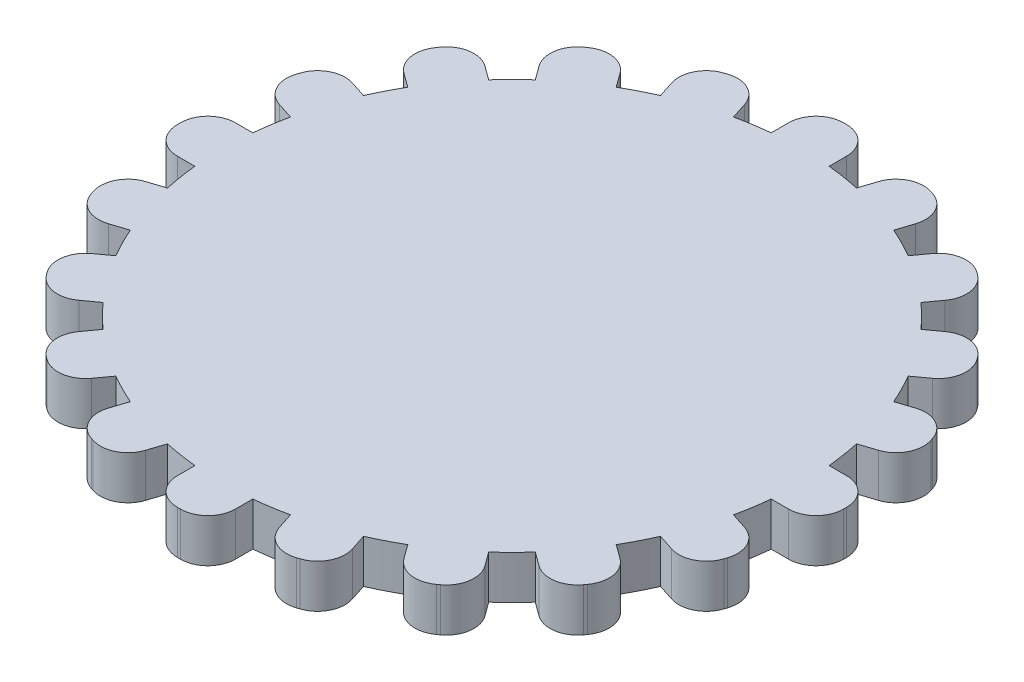
from build123d import *

# Parameters (mm, degrees)
BOSS_EXTRUDE3_DEPTH = 3
BOSS_EXTRUDE4_DEPTH = 3


with BuildPart() as part:
    # Sketch2 → Boss-Extrude3 (new body)
    with BuildSketch(Plane(origin=(0, 0, 0), x_dir=(1, 0, 0), z_dir=(0, 1, 0))):
        with BuildLine():
            Line((-23, -0.1), (-23, 0.1))
            ThreePointArc((-23, 0.1), (-22.443502884, 1.443502884), (-21.1, 2))
            Line((-21.1, 2), (-19.899748742, 2))
            ThreePointArc((-19.899748742, 2), (-19.753766812, 3.128689301), (-19.543819703, 4.247247513))
            Line((-19.543819703, 4.247247513), (-20.685326483, 4.618145549))
            ThreePointArc((-20.685326483, 4.618145549), (-21.791106589, 5.56257098), (-21.905201574, 7.012285219))
            Line((-21.905201574, 7.012285219), (-21.843398175, 7.202496522))
            ThreePointArc((-21.843398175, 7.202496522), (-20.898972744, 8.308276629), (-19.449258505, 8.422371614))
            Line((-19.449258505, 8.422371614), (-18.307751725, 8.051473578))
            ThreePointArc((-18.307751725, 8.051473578), (-17.820130484, 9.079809995), (-17.274805421, 10.078744846))
            Line((-17.274805421, 10.078744846), (-18.245829086, 10.784234835))
            ThreePointArc((-18.245829086, 10.784234835), (-19.005644954, 12.02414164), (-18.666169396, 13.438159103))
            Line((-18.666169396, 13.438159103), (-18.548612345, 13.599962502))
            ThreePointArc((-18.548612345, 13.599962502), (-17.30870554, 14.35977837), (-15.894688077, 14.020302812))
            Line((-15.894688077, 14.020302812), (-14.923664412, 13.314812824))
            ThreePointArc((-14.923664412, 13.314812824), (-14.142135624, 14.142135624), (-13.314812824, 14.923664412))
            Line((-13.314812824, 14.923664412), (-14.020302812, 15.894688077))
            ThreePointArc((-14.020302812, 15.894688077), (-14.35977837, 17.30870554), (-13.599962502, 18.548612345))
            Line((-13.599962502, 18.548612345), (-13.438159103, 18.666169396))
            ThreePointArc((-13.438159103, 18.666169396), (-12.02414164, 19.005644954), (-10.784234835, 18.245829086))
            Line((-10.784234835, 18.245829086), (-10.078744846, 17.274805421))
            ThreePointArc((-10.078744846, 17.274805421), (-9.079809995, 17.820130484), (-8.051473578, 18.307751725))
            Line((-8.051473578, 18.307751725), (-8.422371614, 19.449258505))
            ThreePointArc((-8.422371614, 19.449258505), (-8.308276629, 20.898972744), (-7.202496522, 21.843398175))
            Line((-7.202496522, 21.843398175), (-7.012285219, 21.905201574))
            ThreePointArc((-7.012285219, 21.905201574), (-5.56257098, 21.791106589), (-4.618145549, 20.685326483))
            Line((-4.618145549, 20.685326483), (-4.247247513, 19.543819703))
            ThreePointArc((-4.247247513, 19.543819703), (-3.128689301, 19.753766812), (-2, 19.899748742))
            Line((-2, 19.899748742), (-2, 21.1))
            ThreePointArc((-2, 21.1), (-1.443502884, 22.443502884), (-0.1, 23))
            Line((-0.1, 23), (0.1, 23))
            ThreePointArc((0.1, 23), (1.443502884, 22.443502884), (2, 21.1))
            Line((2, 21.1), (2, 19.899748742))
            ThreePointArc((2, 19.899748742), (3.128689301, 19.753766812), (4.247247513, 19.543819703))
            Line((4.247247513, 19.543819703), (4.618145549, 20.685326483))
            ThreePointArc((4.618145549, 20.685326483), (5.56257098, 21.791106589), (7.012285219, 21.905201574))
            Line((7.012285219, 21.905201574), (7.202496522, 21.843398175))
            ThreePointArc((7.202496522, 21.843398175), (8.308276629, 20.898972744), (8.422371614, 19.449258505))
            Line((8.422371614, 19.449258505), (8.051473578, 18.307751725))
            ThreePointArc((8.051473578, 18.307751725), (9.079809995, 17.820130484), (10.078744846, 17.274805421))
            Line((10.078744846, 17.274805421), (10.784234835, 18.245829086))
            ThreePointArc((10.784234835, 18.245829086), (12.02414164, 19.005644954), (13.438159103, 18.666169396))
            Line((13.438159103, 18.666169396), (13.599962502, 18.548612345))
            ThreePointArc((13.599962502, 18.548612345), (14.35977837, 17.30870554), (14.020302812, 15.894688077))
            Line((14.020302812, 15.894688077), (13.314812824, 14.923664412))
            ThreePointArc((13.314812824, 14.923664412), (14.142135624, 14.142135624), (14.923664412, 13.314812824))
            Line((14.923664412, 13.314812824), (15.894688077, 14.020302812))
            ThreePointArc((15.894688077, 14.020302812), (17.30870554, 14.35977837), (18.548612345, 13.599962502))
            Line((18.548612345, 13.599962502), (18.666169396, 13.438159103))
            ThreePointArc((18.666169396, 13.438159103), (19.005644954, 12.02414164), (18.245829086, 10.784234835))
            Line((18.245829086, 10.784234835), (17.274805421, 10.078744846))
            ThreePointArc((17.274805421, 10.078744846), (17.820130484, 9.079809995), (18.307751725, 8.051473578))
            Line((18.307751725, 8.051473578), (19.449258505, 8.422371614))
            ThreePointArc((19.449258505, 8.422371614), (20.898972744, 8.308276629), (21.843398175, 7.202496522))
            Line((21.843398175, 7.202496522), (21.905201574, 7.012285219))
            ThreePointArc((21.905201574, 7.012285219), (21.791106589, 5.56257098), (20.685326483, 4.618145549))
            Line((20.685326483, 4.618145549), (19.543819703, 4.247247513))
            ThreePointArc((19.543819703, 4.247247513), (19.753766812, 3.128689301), (19.899748742, 2))
            Line((19.899748742, 2), (21.1, 2))
            ThreePointArc((21.1, 2), (22.443502884, 1.443502884), (23, 0.1))
            Line((23, 0.1), (23, -0.1))
            ThreePointArc((23, -0.1), (22.443502884, -1.443502884), (21.1, -2))
            Line((21.1, -2), (19.899748742, -2))
            ThreePointArc((19.899748742, -2), (19.753766812, -3.128689301), (19.543819703, -4.247247513))
            Line((19.543819703, -4.247247513), (20.685326483, -4.618145549))
            ThreePointArc((20.685326483, -4.618145549), (21.791106589, -5.56257098), (21.905201574, -7.012285219))
            Line((21.905201574, -7.012285219), (21.843398175, -7.202496522))
            ThreePointArc((21.843398175, -7.202496522), (20.898972744, -8.308276629), (19.449258505, -8.422371614))
            Line((19.449258505, -8.422371614), (18.307751725, -8.051473578))
            ThreePointArc((18.307751725, -8.051473578), (17.820130484, -9.079809995), (17.274805421, -10.078744846))
            Line((17.274805421, -10.078744846), (18.245829086, -10.784234835))
            ThreePointArc((18.245829086, -10.784234835), (19.005644954, -12.02414164), (18.666169396, -13.438159103))
            Line((18.666169396, -13.438159103), (18.548612345, -13.599962502))
            ThreePointArc((18.548612345, -13.599962502), (17.30870554, -14.35977837), (15.894688077, -14.020302812))
            Line((15.894688077, -14.020302812), (14.923664412, -13.314812824))
            ThreePointArc((14.923664412, -13.314812824), (14.142135624, -14.142135624), (13.314812824, -14.923664412))
            Line((13.314812824, -14.923664412), (14.020302812, -15.894688077))
            ThreePointArc((14.020302812, -15.894688077), (14.35977837, -17.30870554), (13.599962502, -18.548612345))
            Line((13.599962502, -18.548612345), (13.438159103, -18.666169396))
            ThreePointArc((13.438159103, -18.666169396), (12.02414164, -19.005644954), (10.784234835, -18.245829086))
            Line((10.784234835, -18.245829086), (10.078744846, -17.274805421))
            ThreePointArc((10.078744846, -17.274805421), (9.079809995, -17.820130484), (8.051473578, -18.307751725))
            Line((8.051473578, -18.307751725), (8.422371614, -19.449258505))
            ThreePointArc((8.422371614, -19.449258505), (8.308276629, -20.898972744), (7.202496522, -21.843398175))
            Line((7.202496522, -21.843398175), (7.012285219, -21.905201574))
            ThreePointArc((7.012285219, -21.905201574), (5.56257098, -21.791106589), (4.618145549, -20.685326483))
            Line((4.618145549, -20.685326483), (4.247247513, -19.543819703))
            ThreePointArc((4.247247513, -19.543819703), (3.128689301, -19.753766812), (2, -19.899748742))
            Line((2, -19.899748742), (2, -21.1))
            ThreePointArc((2, -21.1), (1.443502884, -22.443502884), (0.1, -23))
            Line((0.1, -23), (-0.1, -23))
            ThreePointArc((-0.1, -23), (-1.443502884, -22.443502884), (-2, -21.1))
            Line((-2, -21.1), (-2, -19.899748742))
            ThreePointArc((-2, -19.899748742), (-3.128689301, -19.753766812), (-4.247247513, -19.543819703))
            Line((-4.247247513, -19.543819703), (-4.618145549, -20.685326483))
            ThreePointArc((-4.618145549, -20.685326483), (-5.56257098, -21.791106589), (-7.012285219, -21.905201574))
            Line((-7.012285219, -21.905201574), (-7.202496522, -21.843398175))
            ThreePointArc((-7.202496522, -21.843398175), (-8.308276629, -20.898972744), (-8.422371614, -19.449258505))
            Line((-8.422371614, -19.449258505), (-8.051473578, -18.307751725))
            ThreePointArc((-8.051473578, -18.307751725), (-9.079809995, -17.820130484), (-10.078744846, -17.274805421))
            Line((-10.078744846, -17.274805421), (-10.784234835, -18.245829086))
            ThreePointArc((-10.784234835, -18.245829086), (-12.02414164, -19.005644954), (-13.438159103, -18.666169396))
            Line((-13.438159103, -18.666169396), (-13.599962502, -18.548612345))
            ThreePointArc((-13.599962502, -18.548612345), (-14.35977837, -17.30870554), (-14.020302812, -15.894688077))
            Line((-14.020302812, -15.894688077), (-13.314812824, -14.923664412))
            ThreePointArc((-13.314812824, -14.923664412), (-14.142135624, -14.142135624), (-14.923664412, -13.314812824))
            Line((-14.923664412, -13.314812824), (-15.894688077, -14.020302812))
            ThreePointArc((-15.894688077, -14.020302812), (-17.30870554, -14.35977837), (-18.548612345, -13.599962502))
            Line((-18.548612345, -13.599962502), (-18.666169396, -13.438159103))
            ThreePointArc((-18.666169396, -13.438159103), (-19.005644954, -12.02414164), (-18.245829086, -10.784234835))
            Line((-18.245829086, -10.784234835), (-17.274805421, -10.078744846))
            ThreePointArc((-17.274805421, -10.078744846), (-17.820130484, -9.079809995), (-18.307751725, -8.051473578))
            Line((-18.307751725, -8.051473578), (-19.449258505, -8.422371614))
            ThreePointArc((-19.449258505, -8.422371614), (-20.898972744, -8.308276629), (-21.843398175, -7.202496522))
            Line((-21.843398175, -7.202496522), (-21.905201574, -7.012285219))
            ThreePointArc((-21.905201574, -7.012285219), (-21.791106589, -5.56257098), (-20.685326483, -4.618145549))
            Line((-20.685326483, -4.618145549), (-19.543819703, -4.247247513))
            ThreePointArc((-19.543819703, -4.247247513), (-19.753766812, -3.128689301), (-19.899748742, -2))
            Line((-19.899748742, -2), (-21.1, -2))
            ThreePointArc((-21.1, -2), (-22.443502884, -1.443502884), (-23, -0.1))
        make_face()
    extrude(amount=BOSS_EXTRUDE3_DEPTH)


with BuildPart() as body_2:
    # Sketch1 → Boss-Extrude4 (new body)
    with BuildSketch(Plane(origin=(0, 0, 0), x_dir=(1, 0, 0), z_dir=(0, 1, 0))):
        with BuildLine():
            Line((-13, 0), (-2.5, 0))
            Line((-2.5, 0), (-2.5, 1.5))
            Line((-2.5, 1.5), (0, 1.5))
            Line((0, 1.5), (0, 10))
            ThreePointArc((0, 10), (-0.563707749, 9.984099037), (-1.1256228, 9.936446715))
            Line((-1.1256228, 9.936446715), (-1.527975605, 11.17476132))
            ThreePointArc((-1.527975605, 11.17476132), (-2.472401036, 12.280541426), (-3.922115275, 12.394636411))
            Line((-3.922115275, 12.394636411), (-4.112326579, 12.332833012))
            ThreePointArc((-4.112326579, 12.332833012), (-5.218106685, 11.388407581), (-5.33220167, 9.938693342))
            Line((-5.33220167, 9.938693342), (-4.929848865, 8.700378737))
            ThreePointArc((-4.929848865, 8.700378737), (-5.877852523, 8.090169944), (-6.751144813, 7.377129775))
            Line((-6.751144813, 7.377129775), (-7.804518133, 8.142450289))
            ThreePointArc((-7.804518133, 8.142450289), (-9.218535596, 8.481925847), (-10.458442402, 7.722109979))
            Line((-10.458442402, 7.722109979), (-10.575999452, 7.56030658))
            ThreePointArc((-10.575999452, 7.56030658), (-10.91547501, 6.146289117), (-10.155659142, 4.906382312))
            Line((-10.155659142, 4.906382312), (-9.102285822, 4.141061797))
            ThreePointArc((-9.102285822, 4.141061797), (-9.510565163, 3.090169944), (-9.797958971, 2))
            Line((-9.797958971, 2), (-11.1, 2))
            ThreePointArc((-11.1, 2), (-12.443502884, 1.443502884), (-13, 0.1))
            Line((-13, 0.1), (-13, 0))
        make_face()
        with BuildLine():
            Line((2.5, 1.5), (2.5, 0))
            Line((2.5, 0), (13, 0))
            Line((13, 0), (13, 0.1))
            ThreePointArc((13, 0.1), (12.443502884, 1.443502884), (11.1, 2))
            Line((11.1, 2), (9.797958971, 2))
            ThreePointArc((9.797958971, 2), (9.510565163, 3.090169944), (9.102285822, 4.141061797))
            Line((9.102285822, 4.141061797), (10.155659142, 4.906382312))
            ThreePointArc((10.155659142, 4.906382312), (10.91547501, 6.146289117), (10.575999452, 7.56030658))
            Line((10.575999452, 7.56030658), (10.458442402, 7.722109979))
            ThreePointArc((10.458442402, 7.722109979), (9.218535596, 8.481925847), (7.804518133, 8.142450289))
            Line((7.804518133, 8.142450289), (6.751144813, 7.377129775))
            ThreePointArc((6.751144813, 7.377129775), (5.877852523, 8.090169944), (4.929848865, 8.700378737))
            Line((4.929848865, 8.700378737), (5.33220167, 9.938693342))
            ThreePointArc((5.33220167, 9.938693342), (5.218106685, 11.388407581), (4.112326579, 12.332833012))
            Line((4.112326579, 12.332833012), (3.922115275, 12.394636411))
            ThreePointArc((3.922115275, 12.394636411), (2.472401036, 12.280541426), (1.527975605, 11.17476132))
            Line((1.527975605, 11.17476132), (1.1256228, 9.936446715))
            ThreePointArc((1.1256228, 9.936446715), (0.563707749, 9.984099037), (0, 10))
            Line((0, 10), (0, 1.5))
            Line((0, 1.5), (2.5, 1.5))
        make_face()
        with BuildLine():
            Line((0, -1.5), (0, -10))
            ThreePointArc((0, -10), (0.563707749, -9.984099037), (1.1256228, -9.936446715))
            Line((1.1256228, -9.936446715), (1.527975605, -11.17476132))
            ThreePointArc((1.527975605, -11.17476132), (2.472401036, -12.280541426), (3.922115275, -12.394636411))
            Line((3.922115275, -12.394636411), (4.112326579, -12.332833012))
            ThreePointArc((4.112326579, -12.332833012), (5.218106685, -11.388407581), (5.33220167, -9.938693342))
            Line((5.33220167, -9.938693342), (4.929848865, -8.700378737))
            ThreePointArc((4.929848865, -8.700378737), (5.877852523, -8.090169944), (6.751144813, -7.377129775))
            Line((6.751144813, -7.377129775), (7.804518133, -8.142450289))
            ThreePointArc((7.804518133, -8.142450289), (9.218535596, -8.481925847), (10.458442402, -7.722109979))
            Line((10.458442402, -7.722109979), (10.575999452, -7.56030658))
            ThreePointArc((10.575999452, -7.56030658), (10.91547501, -6.146289117), (10.155659142, -4.906382312))
            Line((10.155659142, -4.906382312), (9.102285822, -4.141061797))
            ThreePointArc((9.102285822, -4.141061797), (9.510565163, -3.090169944), (9.797958971, -2))
            Line((9.797958971, -2), (11.1, -2))
            ThreePointArc((11.1, -2), (12.443502884, -1.443502884), (13, -0.1))
            Line((13, -0.1), (13, 0))
            Line((13, 0), (2.5, 0))
            Line((2.5, 0), (2.5, -1.5))
            Line((2.5, -1.5), (0, -1.5))
        make_face()
        with BuildLine():
            ThreePointArc((-1.1256228, -9.936446715), (-0.563707749, -9.984099037), (0, -10))
            Line((0, -10), (0, -1.5))
            Line((0, -1.5), (-2.5, -1.5))
            Line((-2.5, -1.5), (-2.5, 0))
            Line((-2.5, 0), (-13, 0))
            Line((-13, 0), (-13, -0.1))
            ThreePointArc((-13, -0.1), (-12.443502884, -1.443502884), (-11.1, -2))
            Line((-11.1, -2), (-9.797958971, -2))
            ThreePointArc((-9.797958971, -2), (-9.510565163, -3.090169944), (-9.102285822, -4.141061797))
            Line((-9.102285822, -4.141061797), (-10.155659142, -4.906382312))
            ThreePointArc((-10.155659142, -4.906382312), (-10.91547501, -6.146289117), (-10.575999452, -7.56030658))
            Line((-10.575999452, -7.56030658), (-10.458442402, -7.722109979))
            ThreePointArc((-10.458442402, -7.722109979), (-9.218535596, -8.481925847), (-7.804518133, -8.142450289))
            Line((-7.804518133, -8.142450289), (-6.751144813, -7.377129775))
            ThreePointArc((-6.751144813, -7.377129775), (-5.877852523, -8.090169944), (-4.929848865, -8.700378737))
            Line((-4.929848865, -8.700378737), (-5.33220167, -9.938693342))
            ThreePointArc((-5.33220167, -9.938693342), (-5.218106685, -11.388407581), (-4.112326579, -12.332833012))
            Line((-4.112326579, -12.332833012), (-3.922115275, -12.394636411))
            ThreePointArc((-3.922115275, -12.394636411), (-2.472401036, -12.280541426), (-1.527975605, -11.17476132))
            Line((-1.527975605, -11.17476132), (-1.1256228, -9.936446715))
        make_face()
    extrude(amount=BOSS_EXTRUDE4_DEPTH)


solid = Compound([part.part, body_2.part])
